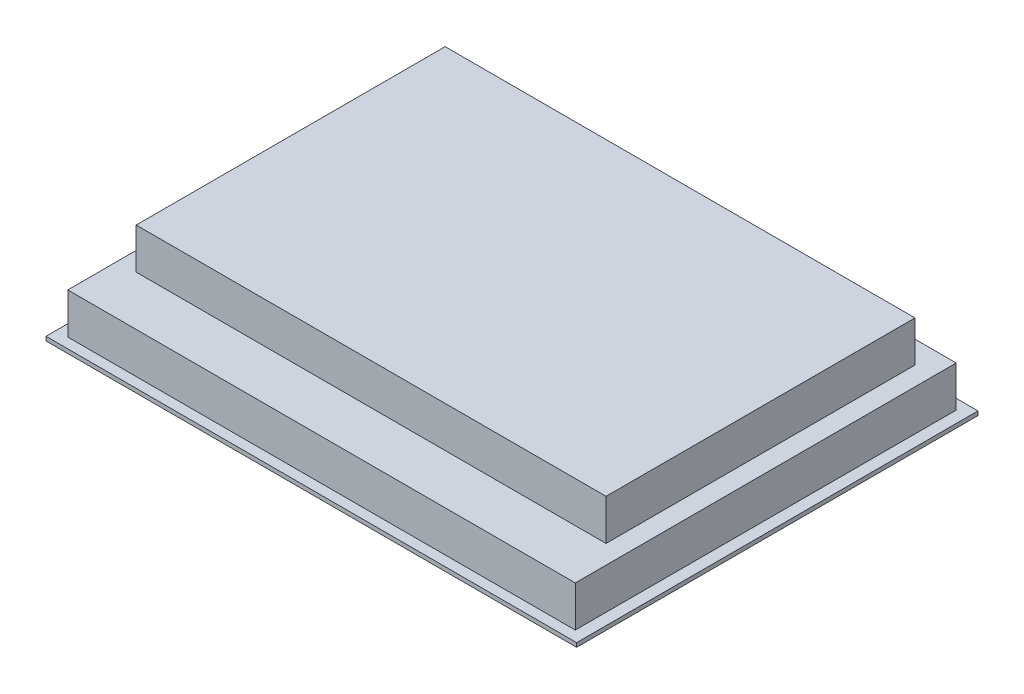
from build123d import *

# Parameters (mm, degrees)
SKETCH_1_W          = 390
SKETCH_1_H          = 295
EXTRUDE_1_DEPTH     = 3
SKETCH_2_W          = 373
SKETCH_2_H          = 280
EXTRUDE_2_DEPTH     = 30
SKETCH_4_W          = 345.33527023
SKETCH_4_H          = 227.069766727
EXTRUDE_3_DEPTH     = 30
SKETCH_5_W          = 304
SKETCH_5_H          = 229
CUT_EXTRUDE_4_DEPTH = 2


with BuildPart() as part:
    # 草图1 → 拉伸1 (new body)
    with BuildSketch(Plane(origin=(0, 0, 0), x_dir=(1, 0, 0), z_dir=(0, 1, 0))):
        Rectangle(SKETCH_1_W, SKETCH_1_H)
    extrude(amount=EXTRUDE_1_DEPTH)

    # 草图2 → 拉伸2 (add)
    with BuildSketch(Plane(origin=(0, 3, 0), x_dir=(1, 0, 0), z_dir=(0, 1, 0))):
        Rectangle(SKETCH_2_W, SKETCH_2_H)
    extrude(amount=EXTRUDE_2_DEPTH)

    # 草图4 → 拉伸3 (add)
    with BuildSketch(Plane(origin=(0, 33, 0), x_dir=(1, 0, 0), z_dir=(0, 1, 0))):
        with Locations((0, 9.986864741)):
            Rectangle(SKETCH_4_W, SKETCH_4_H)
    extrude(amount=EXTRUDE_3_DEPTH)

    # 草图5 → 拉伸4 (cut)
    with BuildSketch(Plane.XZ):
        Rectangle(SKETCH_5_W, SKETCH_5_H)
    extrude(amount=-CUT_EXTRUDE_4_DEPTH, mode=Mode.SUBTRACT)


solid = part.part
